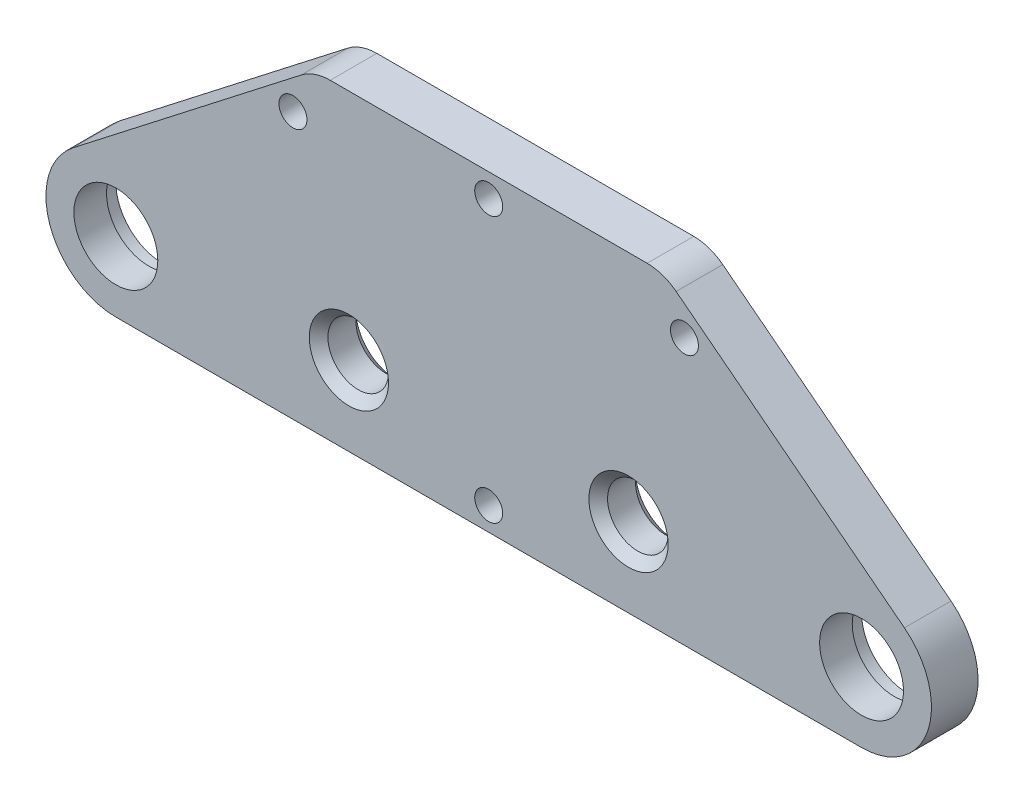
from build123d import *

# Parameters (mm, degrees)
BOSS_EXTRUDE2_DEPTH      = 2.5
SKETCH3_R                = 4.5
CUT_EXTRUDE3_DEPTH       = 8
SKETCH4_R                = 5
CUT_EXTRUDE4_DEPTH       = 1.5
SKETCH5_R                = 3.25
CUT_EXTRUDE5_DEPTH       = 10
CHAMFER6_SIZE            = 1
CHAMFER6_OF_MIRROR7_SIZE = 1
SKETCH6_R                = 2
CUT_EXTRUDE6_DEPTH       = 3
SKETCH7_R                = 1.5
CUT_EXTRUDE7_DEPTH       = 3
SKETCH8_R                = 1.5
CUT_EXTRUDE8_DEPTH       = 3


with BuildPart() as part:
    # Sketch1 → Boss-Extrude2 (new body, symmetric)
    with BuildSketch(Plane.XY):
        with BuildLine():
            Line((-44.599094606, 4.924384255), (-20.111639684, 23.933975293))
            ThreePointArc((-20.111639684, 23.933975293), (-18.64459039, 24.726101678), (-17, 25))
            Line((-17, 25), (17, 25))
            ThreePointArc((17, 25), (18.64459039, 24.726101678), (20.111639684, 23.933975293))
            Line((20.111639684, 23.933975293), (44.599094606, 4.924384255))
            ThreePointArc((44.599094606, 4.924384255), (47.095170256, -3.430752773), (40, -8.5))
            Line((40, -8.5), (-40, -8.5))
            ThreePointArc((-40, -8.5), (-47.095170256, -3.430752773), (-44.599094606, 4.924384255))
        make_face()
    extrude(amount=BOSS_EXTRUDE2_DEPTH, both=True)

    # Sketch3 → Cut-Extrude3 (cut)
    with BuildSketch(Plane(origin=(0, 0, -2.5), x_dir=(-1, 0, 0), z_dir=(0, 0, -1))):
        with Locations((-40, -1)):
            Circle(SKETCH3_R)
    cut_extrude3 = extrude(amount=-CUT_EXTRUDE3_DEPTH, mode=Mode.SUBTRACT)

    # Sketch4 → Cut-Extrude4 (cut)
    with BuildSketch(Plane(origin=(0, 0, -2.5), x_dir=(-1, 0, 0), z_dir=(0, 0, -1))):
        with Locations((-40, -1)):
            Circle(SKETCH4_R)
    cut_extrude4 = extrude(amount=-CUT_EXTRUDE4_DEPTH, mode=Mode.SUBTRACT)

    # Mirror1: Cut-Extrude3, Cut-Extrude4 across plane
    add(cut_extrude3.mirror(Plane(origin=(0, 0, 0), x_dir=(0, 0, 1), z_dir=(1, 0, 0))), mode=Mode.SUBTRACT)
    add(cut_extrude4.mirror(Plane(origin=(0, 0, 0), x_dir=(0, 0, 1), z_dir=(1, 0, 0))), mode=Mode.SUBTRACT)

    # Sketch5 → Cut-Extrude5 (cut)
    with BuildSketch(Plane(origin=(0, 0, -2.5), x_dir=(-1, 0, 0), z_dir=(0, 0, -1))):
        with Locations((-15, 0)):
            Circle(SKETCH5_R)
    cut_extrude5 = extrude(amount=-CUT_EXTRUDE5_DEPTH, mode=Mode.SUBTRACT)

    # Chamfer6
    chamfer6_edges = [part.edges().sort_by_distance(p)[0] for p in [
        (18.25, 0, 2.5),
        (18.25, 0, -2.5),
    ]]
    chamfer(chamfer6_edges, length=CHAMFER6_SIZE)

    # Mirror7: Cut-Extrude5 across plane
    add(cut_extrude5.mirror(Plane(origin=(0, 0, 0), x_dir=(0, 0, 1), z_dir=(1, 0, 0))), mode=Mode.SUBTRACT)

    # Chamfer6 of Mirror7
    chamfer6_of_mirror7_edges = [part.edges().sort_by_distance(p)[0] for p in [
        (-18.25, 0, 2.5),
        (-18.25, 0, -2.5),
    ]]
    chamfer(chamfer6_of_mirror7_edges, length=CHAMFER6_OF_MIRROR7_SIZE)

    # Sketch6 → Cut-Extrude6 (cut)
    with BuildSketch(Plane(origin=(0, 0, -2.5), x_dir=(-1, 0, 0), z_dir=(0, 0, -1))):
        with Locations((0, 15)):
            Circle(SKETCH6_R)
        with Locations((30, 12.5)):
            Circle(SKETCH6_R)
        with Locations((-30, 12.5)):
            Circle(SKETCH6_R)
    extrude(amount=-CUT_EXTRUDE6_DEPTH, mode=Mode.SUBTRACT)

    # Sketch7 → Cut-Extrude7 (cut)
    with BuildSketch(Plane.XY.offset(2.5)):
        with Locations((21, 20.079456047)):
            Circle(SKETCH7_R)
        with Locations((0, -6)):
            Circle(SKETCH7_R)
        with Locations((-21, 20.079456047)):
            Circle(SKETCH7_R)
    extrude(amount=-CUT_EXTRUDE7_DEPTH, mode=Mode.SUBTRACT)

    # Sketch8 → Cut-Extrude8 (cut)
    with BuildSketch(Plane.XY.offset(2.5)):
        with Locations((0, 22.5)):
            Circle(SKETCH8_R)
    extrude(amount=-CUT_EXTRUDE8_DEPTH, mode=Mode.SUBTRACT)


solid = part.part
